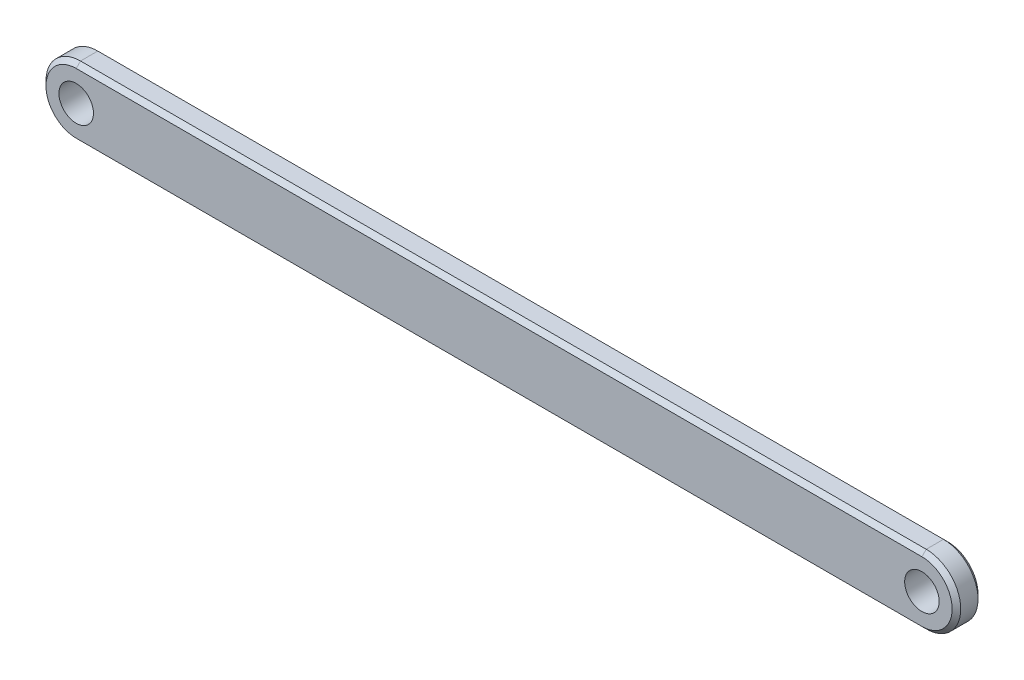
from build123d import *

# Parameters (mm, degrees)
SKETCH1_R           = 2
BOSS_EXTRUDE1_DEPTH = 3
CHAMFER1_SIZE       = 0.5


with BuildPart() as part:
    # Sketch1 → Boss-Extrude1 (new body)
    with BuildSketch(Plane.XY):
        with BuildLine():
            Line((-11.019354839, 4), (86.980645161, 4))
            ThreePointArc((86.980645161, 4), (90.980645161, 0), (86.980645161, -4))
            Line((86.980645161, -4), (-11.019354839, -4))
            ThreePointArc((-11.019354839, -4), (-15.019354839, 0), (-11.019354839, 4))
        make_face()
        with Locations((-11.019354839, 0)):
            Circle(SKETCH1_R, mode=Mode.SUBTRACT)
        with Locations((86.980645161, 0)):
            Circle(SKETCH1_R, mode=Mode.SUBTRACT)
    extrude(amount=BOSS_EXTRUDE1_DEPTH)

    # Chamfer1
    chamfer1_edges = [part.edges().sort_by_distance(p)[0] for p in [
        (90.980645161, 0, 3),
        (37.980645161, 4, 3),
        (-15.019354839, 0, 3),
        (37.980645161, 4, 0),
        (90.980645161, 0, 0),
        (37.980645161, -4, 0),
        (-15.019354839, 0, 0),
        (37.980645161, -4, 3),
    ]]
    chamfer(chamfer1_edges, length=CHAMFER1_SIZE)


solid = part.part
